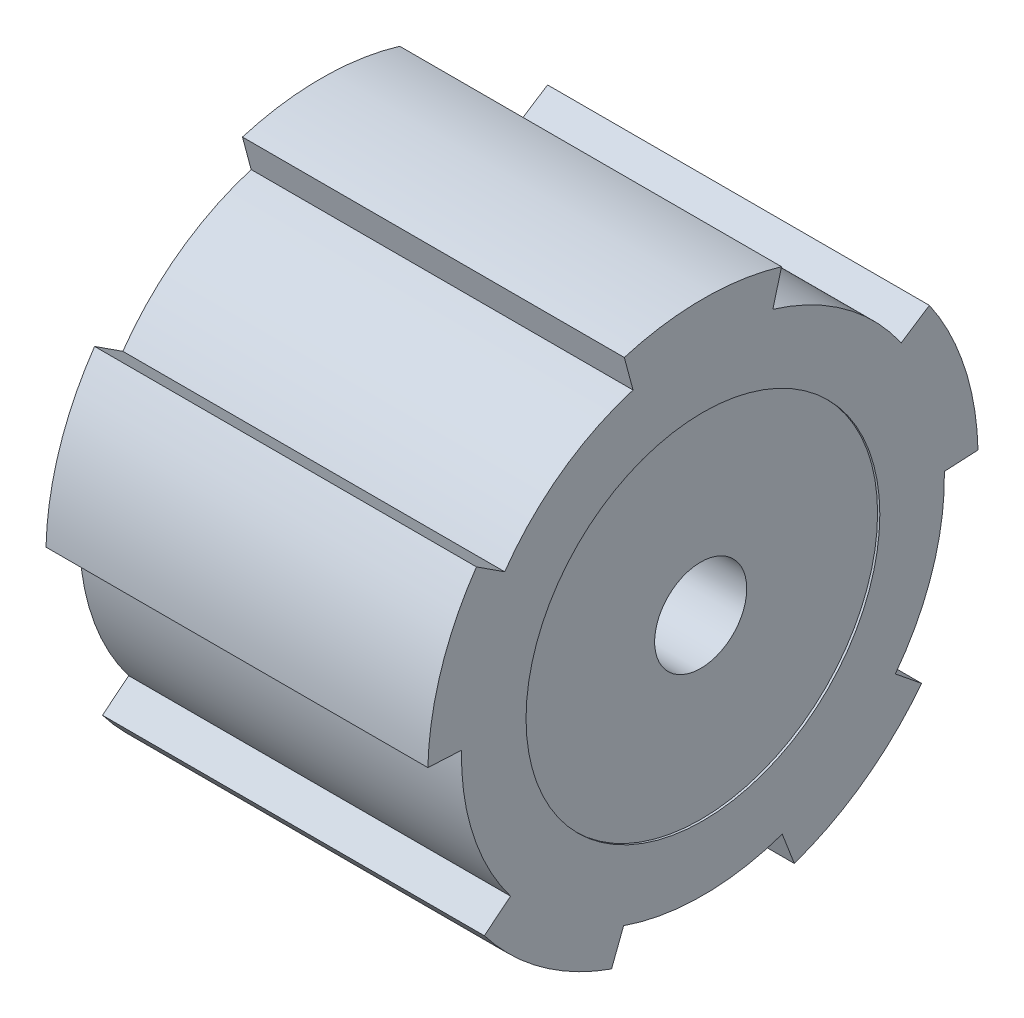
from build123d import *

# Parameters (mm, degrees)
SKETCH4_R                 = 21.5
BOSS_EXTRUDE1_DEPTH       = 34
BOSS_EXTRUDE2_DEPTH       = 34
CIRPATTERN1_COUNT         = 5
SKETCH7_R                 = 10
SHORTSHAFT_KEY1_DEPTH     = 16
SHORTSHAFT_KEY2_DEPTH     = 16
SHORTSHAFT_KEY_PATT_COUNT = 5
SKETCH10_R                = 15.75
PULLEYINDENTATION_DEPTH   = 0.2
SKETCH11_R                = 4.1
METAL_SHAFT_HOLE_DEPTH    = 14.5


with BuildPart() as part:
    # Sketch4 → Boss-Extrude1 (new body)
    with BuildSketch(Plane(origin=(0, 0, 0), x_dir=(0, 0, -1), z_dir=(1, 0, 0))):
        Circle(SKETCH4_R)
    extrude(amount=-BOSS_EXTRUDE1_DEPTH)

    # Sketch5 → Boss-Extrude2 (add)
    with BuildSketch(Plane(origin=(0, 0, 0), x_dir=(0, 0, -1), z_dir=(1, 0, 0))):
        with BuildLine():
            Line((-6.223542865, 20.579541156), (-7, 23.477318635))
            ThreePointArc((-7, 23.477318635), (0, 24.498663031), (7, 23.477318635))
            Line((7, 23.477318635), (6.223542865, 20.579541156))
            ThreePointArc((6.223542865, 20.579541156), (0, 21.5), (-6.223542865, 20.579541156))
        make_face()
    boss_extrude2 = extrude(amount=-BOSS_EXTRUDE2_DEPTH)

    # CirPattern1: Boss-Extrude2 ×5 about axis
    cirpattern1_axis = Axis((0, 0, 0), (1, 0, 0))
    for i in range(1, CIRPATTERN1_COUNT):
        add(boss_extrude2.rotate(cirpattern1_axis, i * 360 / CIRPATTERN1_COUNT))

    # Sketch7 → ShortShaft Key1 (cut)
    with BuildSketch(Plane.ZY.offset(34)):
        Circle(SKETCH7_R)
    extrude(amount=-SHORTSHAFT_KEY1_DEPTH, mode=Mode.SUBTRACT)

    # Sketch8 → ShortShaft Key2 (cut)
    with BuildSketch(Plane.ZY.offset(34)):
        with BuildLine():
            Line((-7.941654077, 6.077016581), (-9.88451898, 7.650317559))
            ThreePointArc((-9.88451898, 7.650317559), (-7.346870668, 10.11209996), (-4.22140002, 11.764814325))
            Line((-4.22140002, 11.764814325), (-3.325480146, 9.430863258))
            ThreePointArc((-3.325480146, 9.430863258), (-5.877852523, 8.090169944), (-7.941654077, 6.077016581))
        make_face()
    shortshaft_key2 = extrude(amount=-SHORTSHAFT_KEY2_DEPTH, mode=Mode.SUBTRACT)

    # ShortShaft Key Patt: ShortShaft Key2 ×5 about axis
    shortshaft_key_patt_axis = Axis((0, 0, 0), (1, 0, 0))
    for i in range(1, SHORTSHAFT_KEY_PATT_COUNT):
        add(shortshaft_key2.rotate(shortshaft_key_patt_axis, i * 360 / SHORTSHAFT_KEY_PATT_COUNT), mode=Mode.SUBTRACT)

    # Sketch10 → PulleyIndentation (cut)
    with BuildSketch(Plane(origin=(0, 0, 0), x_dir=(0, 0, -1), z_dir=(1, 0, 0))):
        Circle(SKETCH10_R)
    extrude(amount=-PULLEYINDENTATION_DEPTH, mode=Mode.SUBTRACT)

    # Sketch11 → Metal Shaft Hole (cut)
    with BuildSketch(Plane(origin=(0, 0, 0), x_dir=(0, 0, -1), z_dir=(1, 0, 0))):
        Circle(SKETCH11_R)
    extrude(amount=-METAL_SHAFT_HOLE_DEPTH, mode=Mode.SUBTRACT)


solid = part.part
